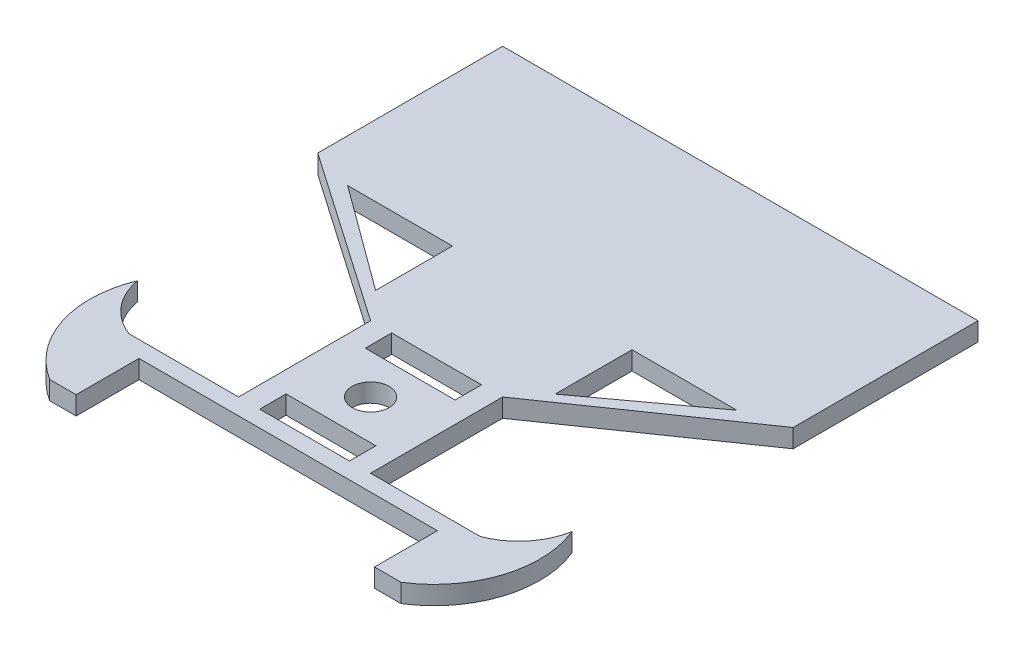
from build123d import *

# Parameters (mm, degrees)
BOSS_EXTRUDE1_DEPTH = 3.5
BOSS_EXTRUDE2_DEPTH = 7
SKETCH6_W           = 34
SKETCH6_H           = 10
CUT_EXTRUDE1_DEPTH  = 7
SKETCH7_R           = 7
CUT_EXTRUDE2_DEPTH  = 7
CUT_EXTRUDE3_DEPTH  = 7
SKETCH11_W          = 113
SKETCH11_H          = 23.8
CUT_EXTRUDE4_DEPTH  = 7


with BuildPart() as part:
    # Sketch1 → Boss-Extrude1 (new body, symmetric)
    with BuildSketch(Plane(origin=(0, 0, 0), x_dir=(1, 0, 0), z_dir=(0, 1, 0))):
        Polygon((90, 0), (-90, 0), (-90, -70), (-25, -115), (-25, -165), (-66.5, -165), (-66.5, -195), (66.5, -195), (66.5, -165), (25, -165), (25, -115), (90, -70), align=None)
    extrude(amount=BOSS_EXTRUDE1_DEPTH, both=True)

    # Sketch2 → Boss-Extrude2 (add)
    with BuildSketch(Plane(origin=(0, 3.5, 0), x_dir=(1, 0, 0), z_dir=(0, 1, 0))):
        with BuildLine():
            Line((-66.5, -165), (-66.5, -195))
            ThreePointArc((-66.5, -195), (-83.296215978, -173.392103188), (-82.268838739, -146.043271918))
            ThreePointArc((-82.268838739, -146.043271918), (-76.884146381, -157.600992268), (-66.5, -165))
        make_face()
        with BuildLine():
            Line((66.5, -165), (66.5, -195))
            ThreePointArc((66.5, -195), (83.296215978, -173.392103188), (82.268838739, -146.043271918))
            ThreePointArc((82.268838739, -146.043271918), (76.884146381, -157.600992268), (66.5, -165))
        make_face()
    extrude(amount=-BOSS_EXTRUDE2_DEPTH)

    # Sketch6 → Cut-Extrude1 (cut)
    with BuildSketch(Plane(origin=(0, 3.5, 0), x_dir=(1, 0, 0), z_dir=(0, 1, 0))):
        with Locations((0, -160)):
            Rectangle(SKETCH6_W, SKETCH6_H)
        with Locations((0, -120)):
            Rectangle(SKETCH6_W, SKETCH6_H)
    extrude(amount=-CUT_EXTRUDE1_DEPTH, mode=Mode.SUBTRACT)

    # Sketch7 → Cut-Extrude2 (cut)
    with BuildSketch(Plane(origin=(0, 3.5, 0), x_dir=(1, 0, 0), z_dir=(0, 1, 0))):
        with Locations((0, -140)):
            Circle(SKETCH7_R)
    extrude(amount=-CUT_EXTRUDE2_DEPTH, mode=Mode.SUBTRACT)

    # Sketch9 → Cut-Extrude3 (cut)
    with BuildSketch(Plane(origin=(0, 3.5, 0), x_dir=(1, 0, 0), z_dir=(0, 1, 0))):
        Polygon((-34, -75), (-73.695942788, -75), (-34, -104.097660068), align=None)
        Polygon((34, -104.097660068), (34, -75), (73.695942788, -75), align=None)
    extrude(amount=-CUT_EXTRUDE3_DEPTH, mode=Mode.SUBTRACT)

    # Sketch11 → Cut-Extrude4 (cut)
    with BuildSketch(Plane(origin=(0, 3.5, 0), x_dir=(1, 0, 0), z_dir=(0, 1, 0))):
        with Locations((0, -183.1)):
            Rectangle(SKETCH11_W, SKETCH11_H)
    extrude(amount=-CUT_EXTRUDE4_DEPTH, mode=Mode.SUBTRACT)


solid = part.part
